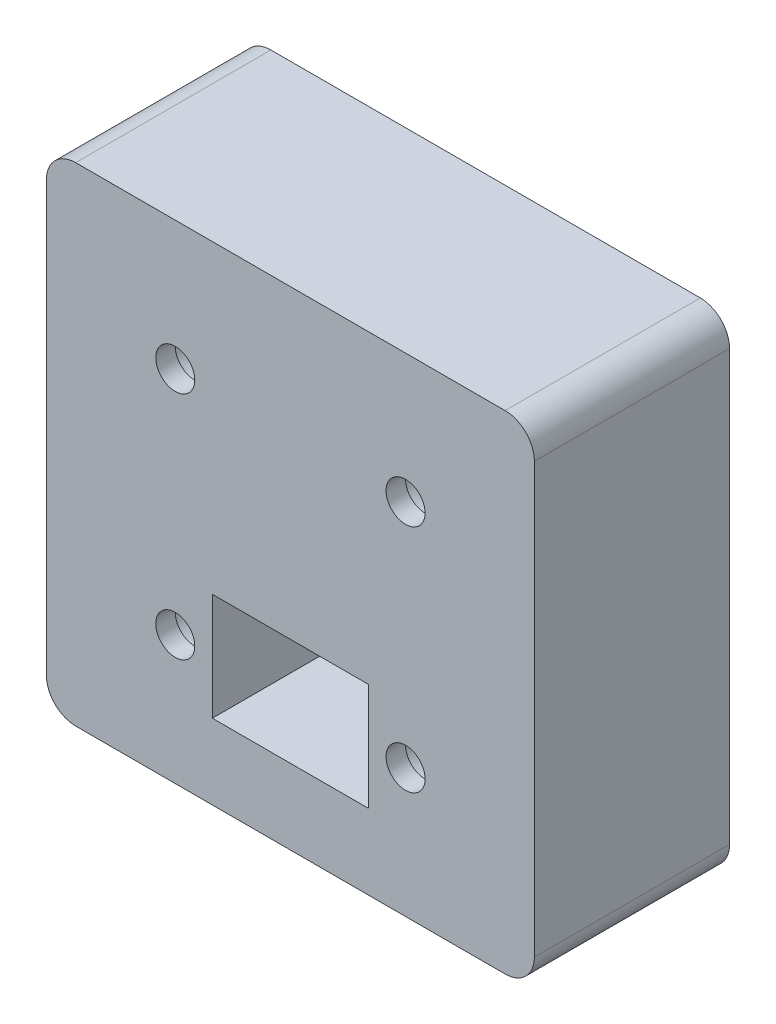
from build123d import *

# Parameters (mm, degrees)
SKETCH1_W           = 50
SKETCH1_H           = 50
SKETCH1_R           = 2
SKETCH1_W_2         = 16
SKETCH1_H_2         = 11
BOSS_EXTRUDE1_DEPTH = 2
SKETCH2_W           = 50
SKETCH2_H           = 50
SKETCH2_R           = 3.1
SKETCH2_W_2         = 16
SKETCH2_H_2         = 11
BOSS_EXTRUDE2_DEPTH = 18
FILLET1_R           = 3


with BuildPart() as part:
    # Sketch1 → Boss-Extrude1 (new body)
    with BuildSketch(Plane.XY):
        Rectangle(SKETCH1_W, SKETCH1_H)
        with Locations((-11.8, 11.8)):
            Circle(SKETCH1_R, mode=Mode.SUBTRACT)
        with Locations((-11.8, -11.8)):
            Circle(SKETCH1_R, mode=Mode.SUBTRACT)
        with Locations((11.8, -11.8)):
            Circle(SKETCH1_R, mode=Mode.SUBTRACT)
        with Locations((11.8, 11.8)):
            Circle(SKETCH1_R, mode=Mode.SUBTRACT)
        with Locations((0, -11.8)):
            Rectangle(SKETCH1_W_2, SKETCH1_H_2, mode=Mode.SUBTRACT)
    extrude(amount=BOSS_EXTRUDE1_DEPTH)

    # Sketch2 → Boss-Extrude2 (add)
    with BuildSketch(Plane(origin=(0, 0, 0), x_dir=(-1, 0, 0), z_dir=(0, 0, -1))):
        Rectangle(SKETCH2_W, SKETCH2_H)
        with Locations((-11.8, -11.8)):
            Circle(SKETCH2_R, mode=Mode.SUBTRACT)
        with Locations((11.8, -11.8)):
            Circle(SKETCH2_R, mode=Mode.SUBTRACT)
        with Locations((11.8, 11.8)):
            Circle(SKETCH2_R, mode=Mode.SUBTRACT)
        with Locations((-11.8, 11.8)):
            Circle(SKETCH2_R, mode=Mode.SUBTRACT)
        with Locations((0, -11.8)):
            Rectangle(SKETCH2_W_2, SKETCH2_H_2, mode=Mode.SUBTRACT)
    extrude(amount=BOSS_EXTRUDE2_DEPTH)

    # Fillet1
    fillet1_edges = [part.edges().sort_by_distance(p)[0] for p in [
        (25, -25, -8),
        (-25, -25, -8),
        (-25, 25, -8),
        (25, 25, -8),
    ]]
    fillet(fillet1_edges, radius=FILLET1_R)


solid = part.part
